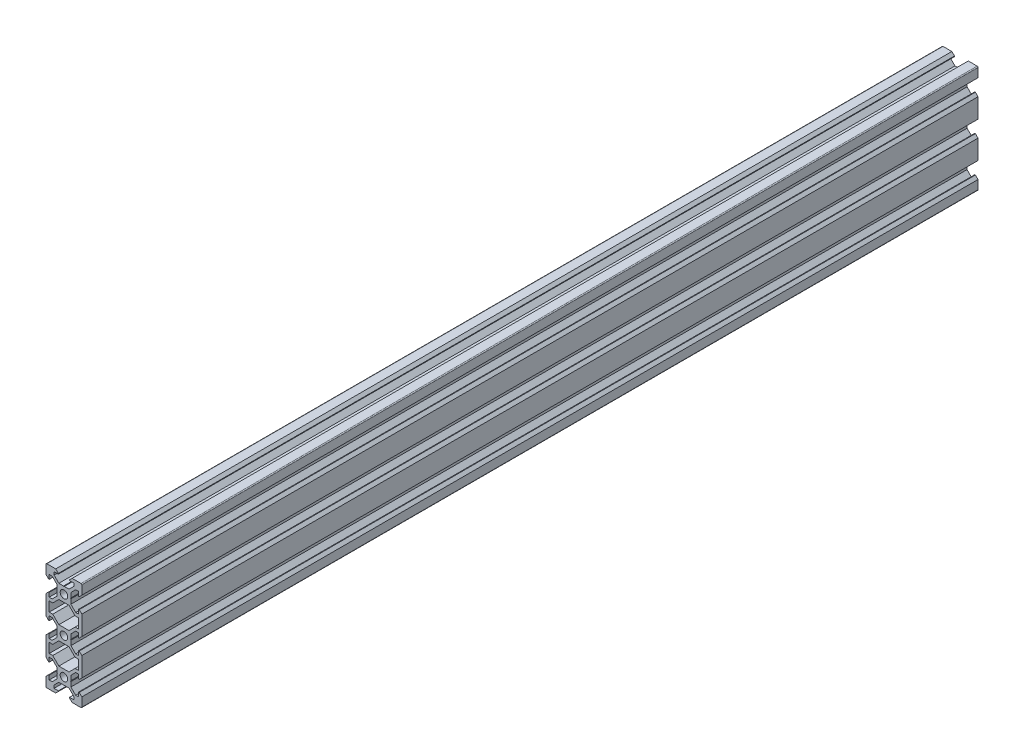
from build123d import *

# Parameters (mm, degrees)
SKETCH1_R           = 2.1
BOSS_EXTRUDE1_DEPTH = 500


with BuildPart() as part:
    # Sketch1 → Boss-Extrude1 (new body)
    with BuildSketch(Plane.XY):
        with BuildLine():
            Line((3.69, 0), (3.9, -0.21))
            Line((3.9, -0.21), (3.9, -2.839339828))
            Line((3.9, -2.839339828), (6.560660172, -5.5))
            Line((6.560660172, -5.5), (8.2, -5.5))
            Line((8.2, -5.5), (8.2, -3.125))
            Line((8.2, -3.125), (8.545, -3.125))
            Line((8.545, -3.125), (10, -4.58))
            Line((10, -4.58), (10, -15.42))
            Line((10, -15.42), (8.545, -16.875))
            Line((8.545, -16.875), (8.2, -16.875))
            Line((8.2, -16.875), (8.2, -14.5))
            Line((8.2, -14.5), (6.560660172, -14.5))
            Line((6.560660172, -14.5), (3.9, -17.160660172))
            Line((3.9, -17.160660172), (3.9, -19.79))
            Line((3.9, -19.79), (3.69, -20))
            Line((3.69, -20), (3.9, -20.21))
            Line((3.9, -20.21), (3.9, -22.839339828))
            Line((3.9, -22.839339828), (6.560660172, -25.5))
            Line((6.560660172, -25.5), (8.2, -25.5))
            Line((8.2, -25.5), (8.2, -23.125))
            Line((8.2, -23.125), (8.545, -23.125))
            Line((8.545, -23.125), (10, -24.58))
            Line((10, -24.58), (10, -35.42))
            Line((10, -35.42), (8.545, -36.875))
            Line((8.545, -36.875), (8.2, -36.875))
            Line((8.2, -36.875), (8.2, -34.5))
            Line((8.2, -34.5), (6.560660172, -34.5))
            Line((6.560660172, -34.5), (3.9, -37.160660172))
            Line((3.9, -37.160660172), (3.9, -39.79))
            Line((3.9, -39.79), (3.69, -40))
            Line((3.69, -40), (3.9, -40.21))
            Line((3.9, -40.21), (3.9, -42.839339828))
            Line((3.9, -42.839339828), (6.560660172, -45.5))
            Line((6.560660172, -45.5), (8.2, -45.5))
            Line((8.2, -45.5), (8.2, -43.125))
            Line((8.2, -43.125), (8.545, -43.125))
            Line((8.545, -43.125), (10, -44.58))
            Line((10, -44.58), (10, -49.5))
            ThreePointArc((10, -49.5), (9.853553391, -49.853553391), (9.5, -50))
            Line((9.5, -50), (4.58, -50))
            Line((4.58, -50), (3.125, -48.545))
            Line((3.125, -48.545), (3.125, -48.2))
            Line((3.125, -48.2), (5.5, -48.2))
            Line((5.5, -48.2), (5.5, -46.560660172))
            Line((5.5, -46.560660172), (2.839339828, -43.9))
            Line((2.839339828, -43.9), (0.21, -43.9))
            Line((0.21, -43.9), (0, -43.69))
            Line((0, -43.69), (-0.21, -43.9))
            Line((-0.21, -43.9), (-2.839339828, -43.9))
            Line((-2.839339828, -43.9), (-5.5, -46.560660172))
            Line((-5.5, -46.560660172), (-5.5, -48.2))
            Line((-5.5, -48.2), (-3.125, -48.2))
            Line((-3.125, -48.2), (-3.125, -48.545))
            Line((-3.125, -48.545), (-4.58, -50))
            Line((-4.58, -50), (-9.5, -50))
            ThreePointArc((-9.5, -50), (-9.853553391, -49.853553391), (-10, -49.5))
            Line((-10, -49.5), (-10, -44.58))
            Line((-10, -44.58), (-8.545, -43.125))
            Line((-8.545, -43.125), (-8.2, -43.125))
            Line((-8.2, -43.125), (-8.2, -45.5))
            Line((-8.2, -45.5), (-6.560660172, -45.5))
            Line((-6.560660172, -45.5), (-3.9, -42.839339828))
            Line((-3.9, -42.839339828), (-3.9, -40.21))
            Line((-3.9, -40.21), (-3.69, -40))
            Line((-3.69, -40), (-3.9, -39.79))
            Line((-3.9, -39.79), (-3.9, -37.160660172))
            Line((-3.9, -37.160660172), (-6.560660172, -34.5))
            Line((-6.560660172, -34.5), (-8.2, -34.5))
            Line((-8.2, -34.5), (-8.2, -36.875))
            Line((-8.2, -36.875), (-8.545, -36.875))
            Line((-8.545, -36.875), (-10, -35.42))
            Line((-10, -35.42), (-10, -24.58))
            Line((-10, -24.58), (-8.545, -23.125))
            Line((-8.545, -23.125), (-8.2, -23.125))
            Line((-8.2, -23.125), (-8.2, -25.5))
            Line((-8.2, -25.5), (-6.560660172, -25.5))
            Line((-6.560660172, -25.5), (-3.9, -22.839339828))
            Line((-3.9, -22.839339828), (-3.9, -20.21))
            Line((-3.9, -20.21), (-3.69, -20))
            Line((-3.69, -20), (-3.9, -19.79))
            Line((-3.9, -19.79), (-3.9, -17.160660172))
            Line((-3.9, -17.160660172), (-6.560660172, -14.5))
            Line((-6.560660172, -14.5), (-8.2, -14.5))
            Line((-8.2, -14.5), (-8.2, -16.875))
            Line((-8.2, -16.875), (-8.545, -16.875))
            Line((-8.545, -16.875), (-10, -15.42))
            Line((-10, -15.42), (-10, -4.58))
            Line((-10, -4.58), (-8.545, -3.125))
            Line((-8.545, -3.125), (-8.2, -3.125))
            Line((-8.2, -3.125), (-8.2, -5.5))
            Line((-8.2, -5.5), (-6.560660172, -5.5))
            Line((-6.560660172, -5.5), (-3.9, -2.839339828))
            Line((-3.9, -2.839339828), (-3.9, -0.21))
            Line((-3.9, -0.21), (-3.69, 0))
            Line((-3.69, 0), (-3.9, 0.21))
            Line((-3.9, 0.21), (-3.9, 2.839339828))
            Line((-3.9, 2.839339828), (-6.560660172, 5.5))
            Line((-6.560660172, 5.5), (-8.2, 5.5))
            Line((-8.2, 5.5), (-8.2, 3.125))
            Line((-8.2, 3.125), (-8.545, 3.125))
            Line((-8.545, 3.125), (-10, 4.58))
            Line((-10, 4.58), (-10, 9.5))
            ThreePointArc((-10, 9.5), (-9.853553391, 9.853553391), (-9.5, 10))
            Line((-9.5, 10), (-4.58, 10))
            Line((-4.58, 10), (-3.125, 8.545))
            Line((-3.125, 8.545), (-3.125, 8.2))
            Line((-3.125, 8.2), (-5.5, 8.2))
            Line((-5.5, 8.2), (-5.5, 6.560660172))
            Line((-5.5, 6.560660172), (-2.839339828, 3.9))
            Line((-2.839339828, 3.9), (-0.21, 3.9))
            Line((-0.21, 3.9), (0, 3.69))
            Line((0, 3.69), (0.21, 3.9))
            Line((0.21, 3.9), (2.839339828, 3.9))
            Line((2.839339828, 3.9), (5.5, 6.560660172))
            Line((5.5, 6.560660172), (5.5, 8.2))
            Line((5.5, 8.2), (3.125, 8.2))
            Line((3.125, 8.2), (3.125, 8.545))
            Line((3.125, 8.545), (4.58, 10))
            Line((4.58, 10), (9.5, 10))
            ThreePointArc((9.5, 10), (9.853553391, 9.853553391), (10, 9.5))
            Line((10, 9.5), (10, 4.58))
            Line((10, 4.58), (8.545, 3.125))
            Line((8.545, 3.125), (8.2, 3.125))
            Line((8.2, 3.125), (8.2, 5.5))
            Line((8.2, 5.5), (6.560660172, 5.5))
            Line((6.560660172, 5.5), (3.9, 2.839339828))
            Line((3.9, 2.839339828), (3.9, 0.21))
            Line((3.9, 0.21), (3.69, 0))
        make_face()
        with Locations((0, -40)):
            Circle(SKETCH1_R, mode=Mode.SUBTRACT)
        with Locations((0, -20)):
            Circle(SKETCH1_R, mode=Mode.SUBTRACT)
        Circle(SKETCH1_R, mode=Mode.SUBTRACT)
        Polygon((-8.2, -32.7), (-6.239339828, -32.7), (-2.839339828, -36.1), (2.839339828, -36.1), (6.239339828, -32.7), (8.2, -32.7), (8.2, -27.3), (6.239339828, -27.3), (2.839339828, -23.9), (-2.839339828, -23.9), (-6.239339828, -27.3), (-8.2, -27.3), align=None, mode=Mode.SUBTRACT)
        Polygon((-8.2, -12.7), (-6.239339828, -12.7), (-2.839339828, -16.1), (2.839339828, -16.1), (6.239339828, -12.7), (8.2, -12.7), (8.2, -7.3), (6.239339828, -7.3), (2.839339828, -3.9), (-2.839339828, -3.9), (-6.239339828, -7.3), (-8.2, -7.3), align=None, mode=Mode.SUBTRACT)
    extrude(amount=BOSS_EXTRUDE1_DEPTH)


solid = part.part
